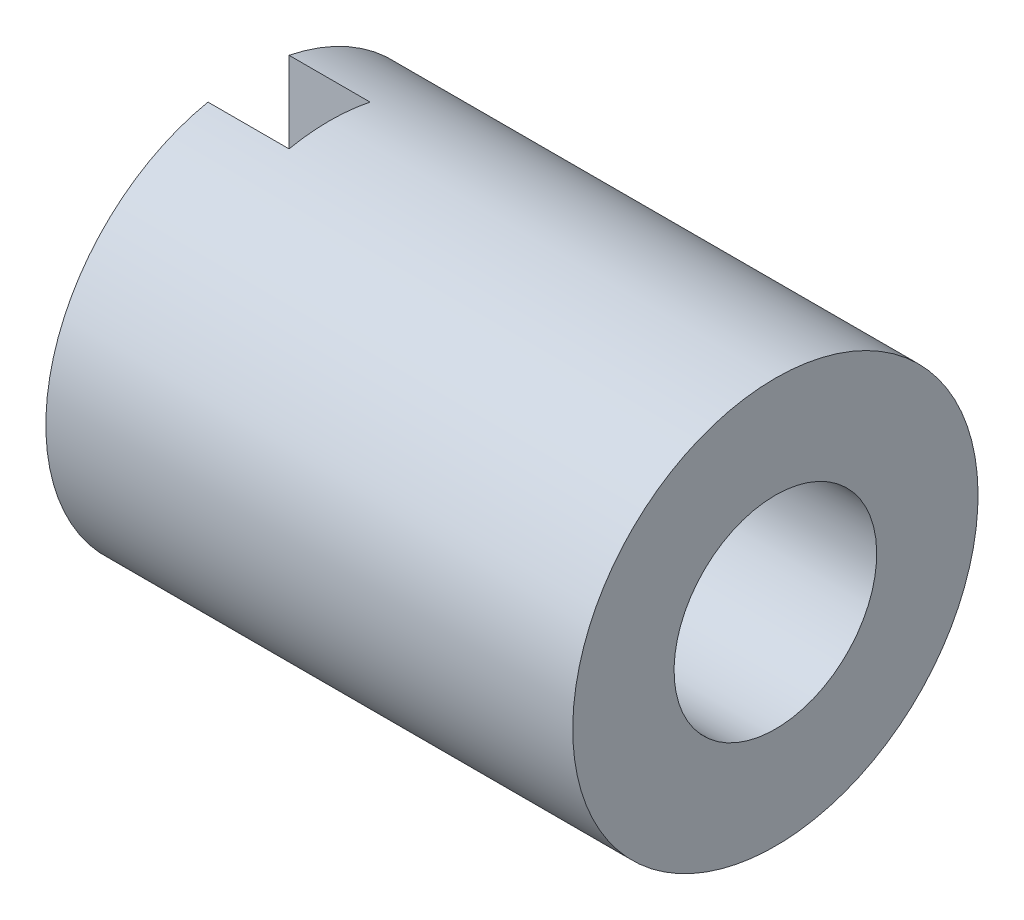
from build123d import *

# Parameters (mm, degrees)
SKETCH2_W          = 1
SKETCH2_H          = 5
CUT_EXTRUDE1_DEPTH = 1


with BuildPart() as part:
    # Sketch1 → Revolve1 (revolve)
    with BuildSketch(Plane.XY):
        Polygon((0, 0), (0, 2.5), (6.5, 2.5), (6.5, 1.25), (2, 1.25), (2, 0), align=None)
    revolve(axis=Axis((2, 0, 0), (-1, 0, 0)))

    # Sketch2 → Cut-Extrude1 (cut)
    with BuildSketch(Plane.ZY):
        Rectangle(SKETCH2_W, SKETCH2_H)
    extrude(amount=-CUT_EXTRUDE1_DEPTH, mode=Mode.SUBTRACT)


solid = part.part
